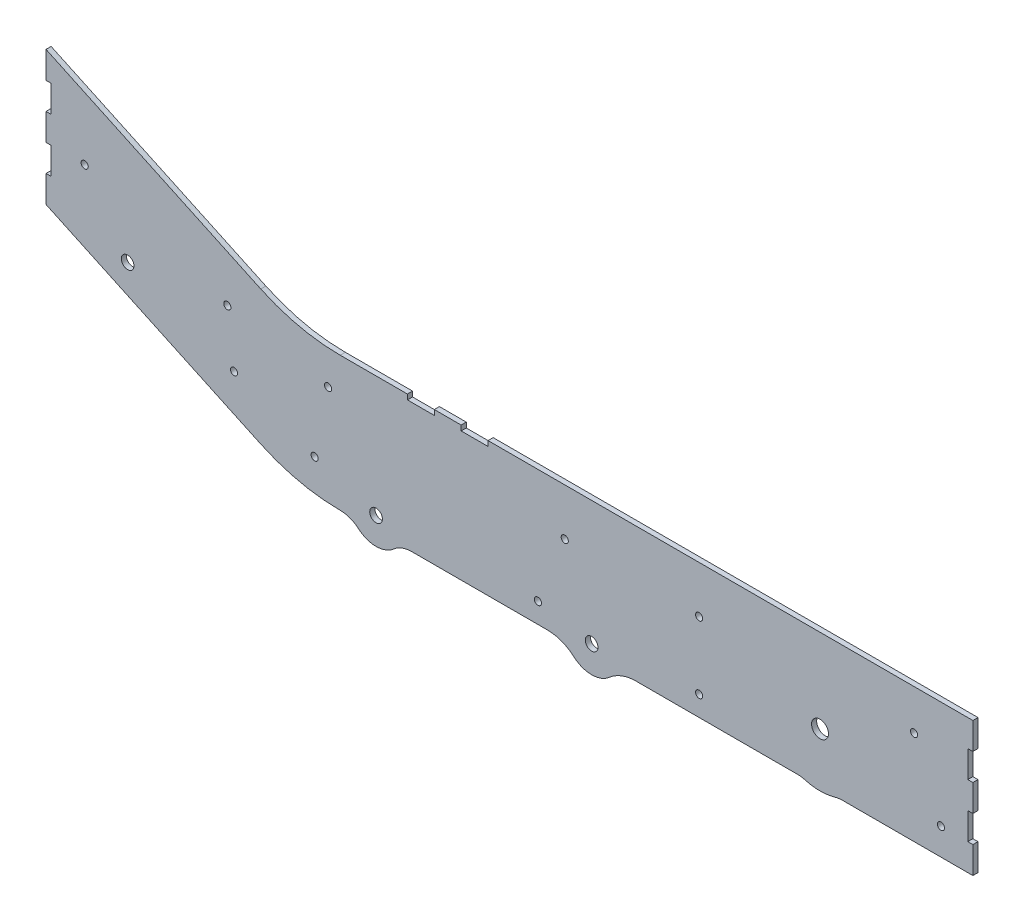
from build123d import *

# Parameters (mm, degrees)
BOSS_EXTRUDE1_DEPTH              = 4.826
SKETCH5_R                        = 3.3782
STANDOFF_HOLE_DEPTH              = 5.826
SKETCH8_W                        = 25.4
SKETCH8_H                        = 4.826
TOP_SLOTS_DEPTH                  = 5.826
BACK_AXLE_EXTENSION_DEPTH        = 4.826
LOWER_SMALL_AXLE_EXTENSION_DEPTH = 4.826
FRONT_SMALL_AXLE_EXTENSION_DEPTH = 4.826
SKETCH10_R                       = 8
SKETCH10_R_2                     = 6
NEW_AXLE_HOLES_DEPTH             = 5.826


with BuildPart() as part:
    # outer face → Boss-Extrude1 (new body)
    with BuildSketch(Plane.XY):
        with BuildLine():
            Line((622.3, 0), (24.193267589, 0))
            ThreePointArc((24.193267589, 0), (-14.28969577, 4.214569934), (-50.948259349, 16.658475465))
            Line((-50.948259349, 16.658475465), (-254, 111.343057132))
            Line((-254, 111.343057132), (-254, 136.743057132))
            Line((-254, 136.743057132), (-249.174, 136.743057132))
            Line((-249.174, 136.743057132), (-249.174, 162.143057132))
            Line((-249.174, 162.143057132), (-254, 162.143057132))
            Line((-254, 162.143057132), (-254, 187.543057132))
            Line((-254, 187.543057132), (-249.174, 187.543057132))
            Line((-249.174, 187.543057132), (-249.174, 212.943057132))
            Line((-249.174, 212.943057132), (-254, 212.943057132))
            Line((-254, 212.943057132), (-254, 238.343057132))
            Line((-254, 238.343057132), (-50.948259349, 143.658475465))
            ThreePointArc((-50.948259349, 143.658475465), (-14.28969577, 131.214569934), (24.193267589, 127))
            Line((24.193267589, 127), (622.3, 127))
            Line((622.3, 127), (622.3, 101.6))
            Line((622.3, 101.6), (617.474, 101.6))
            Line((617.474, 101.6), (617.474, 76.2))
            Line((617.474, 76.2), (622.3, 76.2))
            Line((622.3, 76.2), (622.3, 50.8))
            Line((622.3, 50.8), (617.474, 50.8))
            Line((617.474, 50.8), (617.474, 25.4))
            Line((617.474, 25.4), (622.3, 25.4))
            Line((622.3, 25.4), (622.3, 0))
        make_face()
    extrude(amount=BOSS_EXTRUDE1_DEPTH)

    # Sketch5 → standoff hole (cut, through all)
    with BuildSketch(Plane.XY.offset(4.826)):
        with Locations((-76.2, 63.5)):
            Circle(SKETCH5_R)
        with Locations((-82.55, 114.3)):
            Circle(SKETCH5_R)
        with Locations((592.074, 25.4)):
            Circle(SKETCH5_R)
        with Locations((0, 31.75)):
            Circle(SKETCH5_R)
        with Locations((211.0486, 19.05)):
            Circle(SKETCH5_R)
        with Locations((236.4486, 82.55)):
            Circle(SKETCH5_R)
        with Locations((363.4486, 82.55)):
            Circle(SKETCH5_R)
        with Locations((363.4486, 19.05)):
            Circle(SKETCH5_R)
        with Locations((566.674, 88.9)):
            Circle(SKETCH5_R)
        with Locations((12.7, 95.25)):
            Circle(SKETCH5_R)
        with Locations((-217.424, 162.143057132)):
            Circle(SKETCH5_R)
    extrude(amount=-STANDOFF_HOLE_DEPTH, mode=Mode.SUBTRACT)

    # Sketch8 → top slots (cut, through all)
    with BuildSketch(Plane.XY.offset(4.826)):
        with Locations((100.393267589, 124.587)):
            Rectangle(SKETCH8_W, SKETCH8_H)
        with Locations((151.193267589, 124.587)):
            Rectangle(SKETCH8_W, SKETCH8_H)
    extrude(amount=-TOP_SLOTS_DEPTH, mode=Mode.SUBTRACT)

    # Sketch9 → back axle extension (add)
    with BuildSketch(Plane.XY.offset(4.826)):
        with BuildLine():
            Line((498.944734517, 0), (456.603265483, 0))
            ThreePointArc((456.603265483, 0), (460.166971419, -0.251242575), (463.660176989, -1))
            ThreePointArc((463.660176989, -1), (477.774, -3), (491.887823011, -1))
            ThreePointArc((491.887823011, -1), (495.381028581, -0.251242575), (498.944734517, 0))
        make_face()
    extrude(amount=-BACK_AXLE_EXTENSION_DEPTH)

    # Sketch11 → lower small axle extension (add)
    with BuildSketch(Plane.XY.offset(4.826)):
        with BuildLine():
            Line((303.790106689, 0), (219.957893311, 0))
            ThreePointArc((219.957893311, 0), (233.396420016, -2.448688664), (245.107557324, -9.48))
            ThreePointArc((245.107557324, -9.48), (261.874, -15.8), (278.640442676, -9.48))
            ThreePointArc((278.640442676, -9.48), (290.351579984, -2.448688664), (303.790106689, 0))
        make_face()
    extrude(amount=-LOWER_SMALL_AXLE_EXTENSION_DEPTH)

    # Sketch13 → front small axle extension (add)
    with BuildSketch(Plane.XY.offset(4.826)):
        with BuildLine():
            Line((91.928424908, 0), (24.193267589, 0))
            ThreePointArc((24.193267589, 0), (33.393269649, -1.659006827), (41.434305199, -6.427034599))
            ThreePointArc((41.434305199, -6.427034599), (58.060846248, -12.625), (74.687387297, -6.427034599))
            ThreePointArc((74.687387297, -6.427034599), (82.728422848, -1.659006827), (91.928424908, 0))
        make_face()
    extrude(amount=-FRONT_SMALL_AXLE_EXTENSION_DEPTH)

    # Sketch10 → new axle holes (cut, through all)
    with BuildSketch(Plane.XY.offset(4.826)):
        with Locations((477.774, 47.8)):
            Circle(SKETCH10_R)
        with Locations((261.874, 9.6)):
            Circle(SKETCH10_R_2)
        with Locations((58.060846248, 12.775)):
            Circle(SKETCH10_R_2)
        with Locations((-176.843107922, 102.547565902)):
            Circle(SKETCH10_R_2)
    extrude(amount=-NEW_AXLE_HOLES_DEPTH, mode=Mode.SUBTRACT)


solid = part.part
